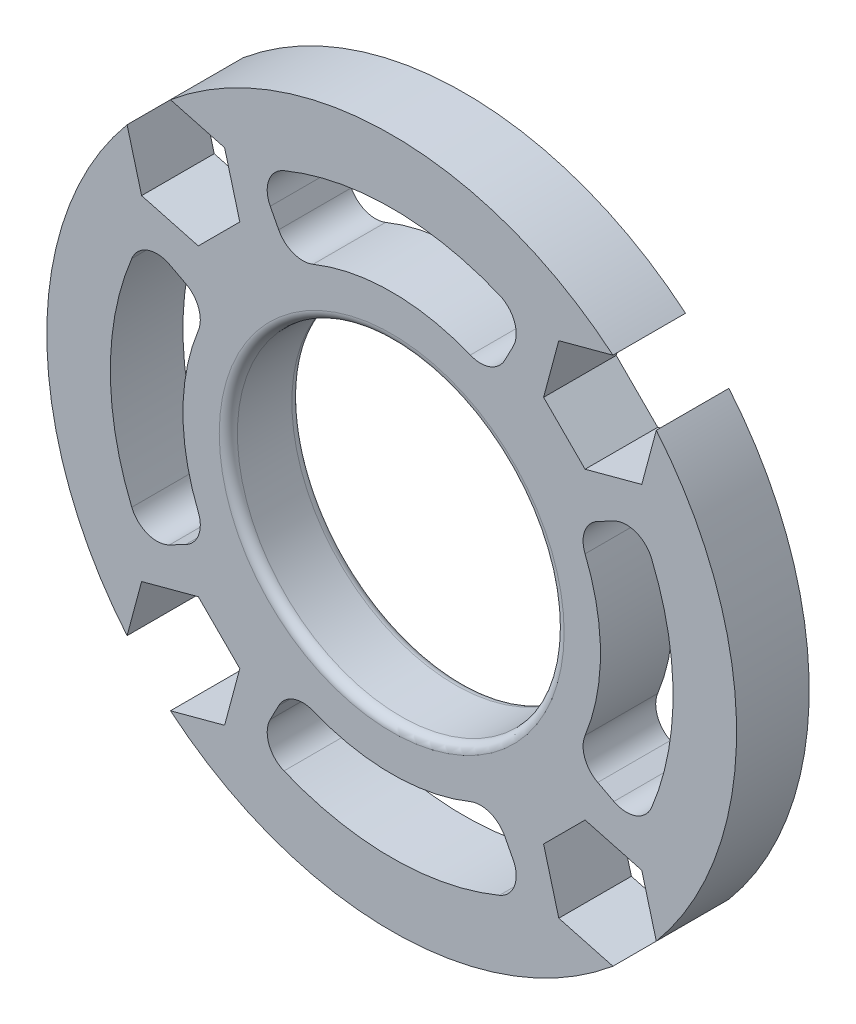
from build123d import *

# Parameters (mm, degrees)
SKETCH1_R           = 19
SKETCH1_R_2         = 9
BOSS_EXTRUDE1_DEPTH = 4
CUT_EXTRUDE1_DEPTH  = 4
FILLET1_R           = 0.5


with BuildPart() as part:
    # Sketch1 → Boss-Extrude1 (new body)
    with BuildSketch(Plane.XY):
        Circle(SKETCH1_R)
        Circle(SKETCH1_R_2, mode=Mode.SUBTRACT)
        with BuildLine():
            Line((6.689691504, 12.241024694), (6.226047976, 11.350373764))
            ThreePointArc((6.226047976, 11.350373764), (5.41320923, 10.635157913), (4.330662681, 10.653420143))
            ThreePointArc((4.330662681, 10.653420143), (0, 11.5), (-4.330662681, 10.653420143))
            ThreePointArc((-4.330662681, 10.653420143), (-5.41320923, 10.635157913), (-6.226047976, 11.350373764))
            Line((-6.226047976, 11.350373764), (-6.689691504, 12.241024694))
            ThreePointArc((-6.689691504, 12.241024694), (-6.768746058, 13.446590252), (-5.933372603, 14.319395572))
            ThreePointArc((-5.933372603, 14.319395572), (0, 15.5), (5.933372603, 14.319395572))
            ThreePointArc((5.933372603, 14.319395572), (6.768746058, 13.446590252), (6.689691504, 12.241024694))
        make_face(mode=Mode.SUBTRACT)
        with BuildLine():
            Line((12.241024694, 6.689691504), (11.350373764, 6.226047976))
            ThreePointArc((11.350373764, 6.226047976), (10.635157913, 5.41320923), (10.653420143, 4.330662681))
            ThreePointArc((10.653420143, 4.330662681), (11.5, 0), (10.653420143, -4.330662681))
            ThreePointArc((10.653420143, -4.330662681), (10.635157913, -5.41320923), (11.350373764, -6.226047976))
            Line((11.350373764, -6.226047976), (12.241024694, -6.689691504))
            ThreePointArc((12.241024694, -6.689691504), (13.446590252, -6.768746058), (14.319395572, -5.933372603))
            ThreePointArc((14.319395572, -5.933372603), (15.5, 0), (14.319395572, 5.933372603))
            ThreePointArc((14.319395572, 5.933372603), (13.446590252, 6.768746058), (12.241024694, 6.689691504))
        make_face(mode=Mode.SUBTRACT)
        with BuildLine():
            Line((6.689691504, -12.241024694), (6.226047976, -11.350373764))
            ThreePointArc((6.226047976, -11.350373764), (5.41320923, -10.635157913), (4.330662681, -10.653420143))
            ThreePointArc((4.330662681, -10.653420143), (0, -11.5), (-4.330662681, -10.653420143))
            ThreePointArc((-4.330662681, -10.653420143), (-5.41320923, -10.635157913), (-6.226047976, -11.350373764))
            Line((-6.226047976, -11.350373764), (-6.689691504, -12.241024694))
            ThreePointArc((-6.689691504, -12.241024694), (-6.768746058, -13.446590252), (-5.933372603, -14.319395572))
            ThreePointArc((-5.933372603, -14.319395572), (0, -15.5), (5.933372603, -14.319395572))
            ThreePointArc((5.933372603, -14.319395572), (6.768746058, -13.446590252), (6.689691504, -12.241024694))
        make_face(mode=Mode.SUBTRACT)
        with BuildLine():
            Line((-12.241024694, -6.689691504), (-11.350373764, -6.226047976))
            ThreePointArc((-11.350373764, -6.226047976), (-10.635157913, -5.41320923), (-10.653420143, -4.330662681))
            ThreePointArc((-10.653420143, -4.330662681), (-11.5, 0), (-10.653420143, 4.330662681))
            ThreePointArc((-10.653420143, 4.330662681), (-10.635157913, 5.41320923), (-11.350373764, 6.226047976))
            Line((-11.350373764, 6.226047976), (-12.241024694, 6.689691504))
            ThreePointArc((-12.241024694, 6.689691504), (-13.446590252, 6.768746058), (-14.319395572, 5.933372603))
            ThreePointArc((-14.319395572, 5.933372603), (-15.5, 0), (-14.319395572, -5.933372603))
            ThreePointArc((-14.319395572, -5.933372603), (-13.446590252, -6.768746058), (-12.241024694, -6.689691504))
        make_face(mode=Mode.SUBTRACT)
    extrude(amount=BOSS_EXTRUDE1_DEPTH)

    # Sketch2 → Cut-Extrude1 (cut)
    with BuildSketch(Plane(origin=(0, 0, 0), x_dir=(-1, 0, 0), z_dir=(0, 0, -1))):
        Polygon((10.65368142, -8.367490994), (8.367490994, -10.65368142), (9.204294768, -13.776675621), (12.327288968, -14.613479395), (14.613479395, -12.327288968), (13.776675621, -9.204294768), align=None)
        Polygon((13.776675621, 9.204294768), (14.613479395, 12.327288968), (12.327288968, 14.613479395), (9.204294768, 13.776675621), (8.367490994, 10.65368142), (10.65368142, 8.367490994), align=None)
        Polygon((-8.367490994, -10.65368142), (-10.65368142, -8.367490994), (-13.776675621, -9.204294768), (-14.613479395, -12.327288968), (-12.327288968, -14.613479395), (-9.204294768, -13.776675621), align=None)
        Polygon((-10.65368142, 8.367490994), (-8.367490994, 10.65368142), (-9.204294768, 13.776675621), (-12.327288968, 14.613479395), (-14.613479395, 12.327288968), (-13.776675621, 9.204294768), align=None)
    extrude(amount=-CUT_EXTRUDE1_DEPTH, mode=Mode.SUBTRACT)

    # Fillet1
    fillet1_edges = [part.edges().sort_by_distance(p)[0] for p in [
        (-9, 0, 0),
        (-9, 0, 4),
    ]]
    fillet(fillet1_edges, radius=FILLET1_R)


solid = part.part
